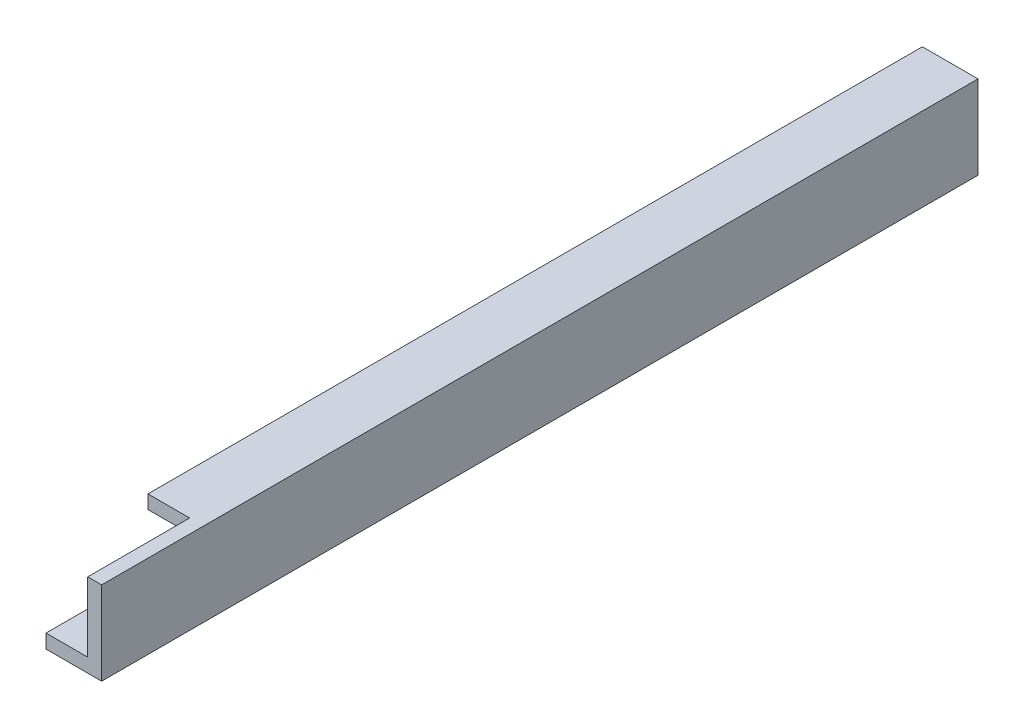
from build123d import *

# Parameters (mm, degrees)
SKETCH2_W           = 25.4
SKETCH2_H           = 400.05
BOSS_EXTRUDE1_DEPTH = 6.35
SKETCH4_W           = 6.35
SKETCH4_H           = 400.05
BOSS_EXTRUDE2_DEPTH = 31.75
SKETCH10_W          = 6.35
SKETCH10_H          = 25.4
BOSS_EXTRUDE6_DEPTH = 19.05
SKETCH12_R          = 4.572
CUT_EXTRUDE3_DEPTH  = 19.05
SKETCH14_W          = 6.35
SKETCH14_H          = 25.4
BOSS_EXTRUDE7_DEPTH = 19.05
SKETCH15_R          = 4.572
CUT_EXTRUDE4_DEPTH  = 19.05
SKETCH16_W          = 353.518259368
SKETCH16_H          = 6.201883549
BOSS_EXTRUDE8_DEPTH = 19.05


with BuildPart() as part:
    # Sketch2 → Boss-Extrude1 (new body)
    with BuildSketch(Plane(origin=(0, 0, 0), x_dir=(1, 0, 0), z_dir=(0, 1, 0))):
        with Locations((12.7, 200.025)):
            Rectangle(SKETCH2_W, SKETCH2_H)
    extrude(amount=BOSS_EXTRUDE1_DEPTH)

    # Sketch4 → Boss-Extrude2 (add)
    with BuildSketch(Plane(origin=(0, 6.35, 0), x_dir=(1, 0, 0), z_dir=(0, 1, 0))):
        with Locations((22.225, 200.025)):
            Rectangle(SKETCH4_W, SKETCH4_H)
    extrude(amount=BOSS_EXTRUDE2_DEPTH)

    # Sketch10 → Boss-Extrude6 (add)
    with BuildSketch(Plane.ZY.offset(-19.05)):
        with Locations((-396.875, 19.198116451)):
            Rectangle(SKETCH10_W, SKETCH10_H)
    extrude(amount=BOSS_EXTRUDE6_DEPTH)

    # Sketch12 → Cut-Extrude3 (cut)
    with BuildSketch(Plane.XY.offset(-393.7)):
        with Locations((12.7, 19.198116451)):
            Circle(SKETCH12_R)
    extrude(amount=-CUT_EXTRUDE3_DEPTH, mode=Mode.SUBTRACT)

    # Sketch14 → Boss-Extrude7 (add)
    with BuildSketch(Plane.ZY.offset(-19.05)):
        with Locations((-263.525, 19.05)):
            Rectangle(SKETCH14_W, SKETCH14_H)
    extrude(amount=BOSS_EXTRUDE7_DEPTH)

    # Sketch15 → Cut-Extrude4 (cut)
    with BuildSketch(Plane.XY.offset(-260.35)):
        with Locations((12.7, 19.05)):
            Circle(SKETCH15_R)
    extrude(amount=-CUT_EXTRUDE4_DEPTH, mode=Mode.SUBTRACT)

    # Sketch16 → Boss-Extrude8 (add)
    with BuildSketch(Plane.ZY.offset(-19.05)):
        with Locations((-223.290870316, 34.999058226)):
            Rectangle(SKETCH16_W, SKETCH16_H)
    extrude(amount=BOSS_EXTRUDE8_DEPTH)


solid = part.part
